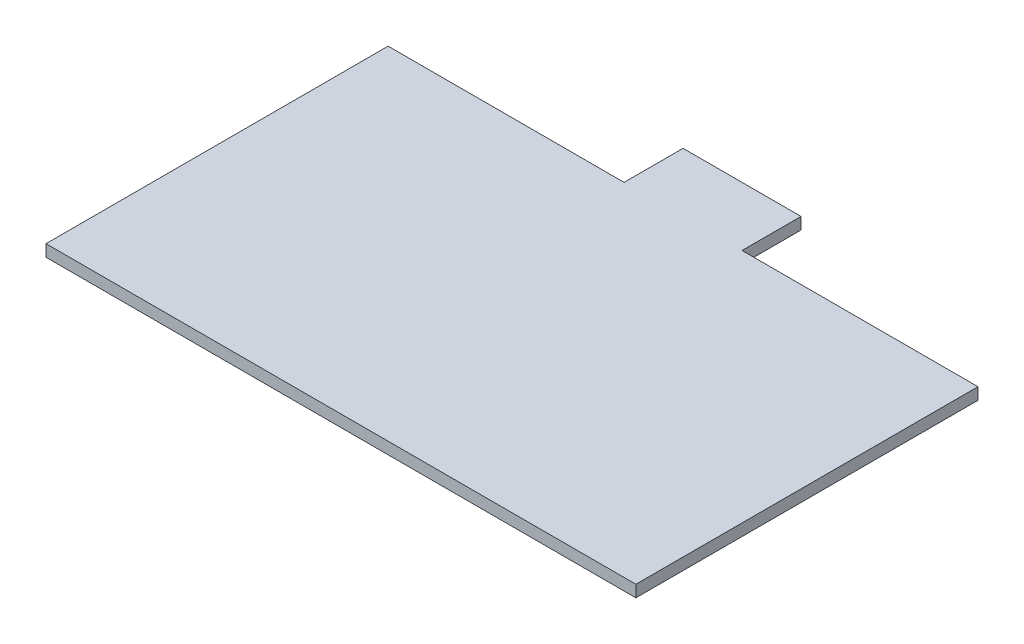
from build123d import *

# Parameters (mm, degrees)
SKETCH1_W           = 10
SKETCH1_H           = 5
SKETCH1_W_2         = 50
SKETCH1_H_2         = 29
BOSS_EXTRUDE4_DEPTH = 1


with BuildPart() as part:
    # Sketch1 → Boss-Extrude4 (new body)
    with BuildSketch(Plane(origin=(0, 0, 0), x_dir=(1, 0, 0), z_dir=(0, 1, 0))):
        with Locations((0, 17)):
            Rectangle(SKETCH1_W, SKETCH1_H)
        Rectangle(SKETCH1_W_2, SKETCH1_H_2)
    extrude(amount=BOSS_EXTRUDE4_DEPTH)


solid = part.part
